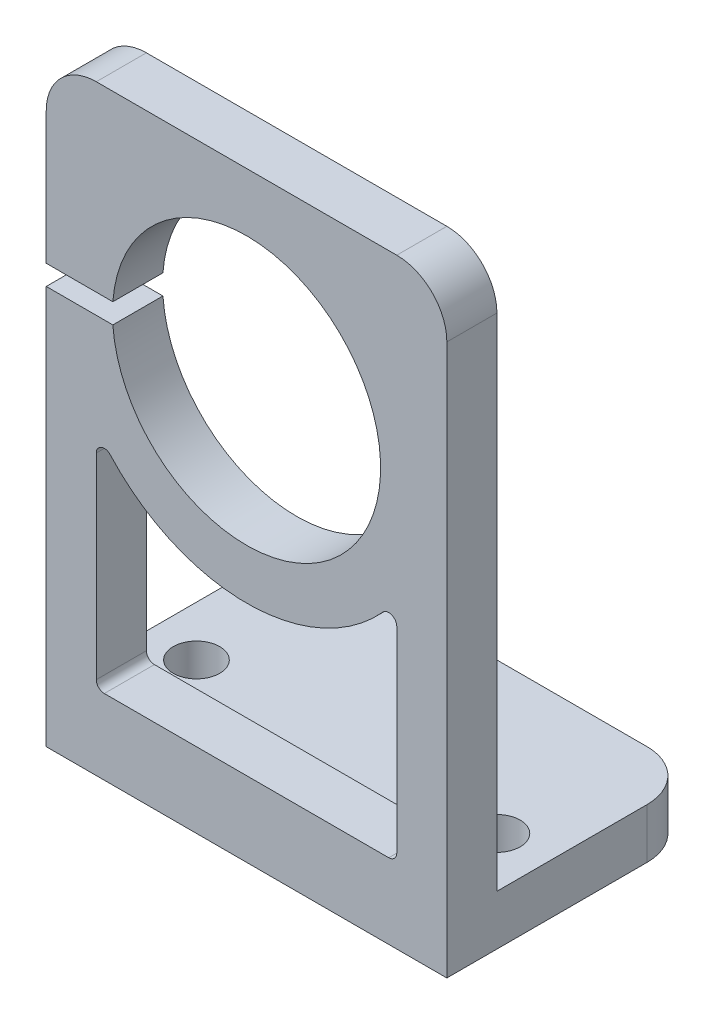
from build123d import *

# Parameters (mm, degrees)
BOSS_EXTRUDE1_DEPTH   = 12.7
SKETCH2_R             = 8.5
CUT_EXTRUDE1_DEPTH    = 16.875
FILLET1_R             = 3.175
F_4_CLEARANCE_HOLE1_D = 2.9464
SKETCH5_W             = 24.88239846
SKETCH5_H             = 1.27
CUT_EXTRUDE2_DEPTH    = 16.875
CUT_EXTRUDE3_DEPTH    = 16.875
FILLET2_R             = 0.508


with BuildPart() as part:
    # Sketch1 → Boss-Extrude1 (new body, symmetric)
    with BuildSketch(Plane(origin=(0, 0, 0), x_dir=(0, 0, -1), z_dir=(1, 0, 0))):
        Polygon((0, 38.1), (0, 0), (15.875, 0), (15.875, 3.175), (3.175, 3.175), (3.175, 38.1), align=None)
    extrude(amount=BOSS_EXTRUDE1_DEPTH, both=True)

    # Sketch2 → Cut-Extrude1 (cut, through all)
    with BuildSketch(Plane.XY):
        with Locations((0, 25.908)):
            Circle(SKETCH2_R)
    extrude(amount=-CUT_EXTRUDE1_DEPTH, mode=Mode.SUBTRACT)

    # Fillet1
    fillet1_edges = [part.edges().sort_by_distance(p)[0] for p in [
        (12.7, 1.5875, -15.875),
        (12.7, 38.1, -1.5875),
        (-12.7, 1.5875, -15.875),
        (-12.7, 38.1, -1.5875),
    ]]
    fillet(fillet1_edges, radius=FILLET1_R)

    # #4 Clearance Hole1 (through all)
    with Locations(Plane(origin=(0, 3.175, 0), x_dir=(1, 0, 0), z_dir=(0, 1, 0))):
        with Locations((-9.525, 6.35), (0, 12.7), (9.525, 6.35)):
            Hole(F_4_CLEARANCE_HOLE1_D / 2)

    # Sketch5 → Cut-Extrude2 (cut, through all)
    with BuildSketch(Plane.XY):
        with Locations((-12.44119923, 25.908)):
            Rectangle(SKETCH5_W, SKETCH5_H)
    extrude(amount=-CUT_EXTRUDE2_DEPTH, mode=Mode.SUBTRACT)

    # Sketch6 → Cut-Extrude3 (cut, through all)
    with BuildSketch(Plane.XY):
        with BuildLine():
            Line((-9.525, 19.156703828), (-9.525, 4.7625))
            Line((-9.525, 4.7625), (9.525, 4.7625))
            Line((9.525, 4.7625), (9.525, 19.156703828))
            ThreePointArc((9.525, 19.156703828), (0, 14.233), (-9.525, 19.156703828))
        make_face()
    extrude(amount=-CUT_EXTRUDE3_DEPTH, mode=Mode.SUBTRACT)

    # Fillet2
    fillet2_edges = [part.edges().sort_by_distance(p)[0] for p in [
        (-9.525, 19.156703828, -1.5875),
        (9.525, 19.156703828, -1.5875),
        (9.525, 4.7625, -1.5875),
        (-9.525, 4.7625, -1.5875),
    ]]
    fillet(fillet2_edges, radius=FILLET2_R)


solid = part.part
